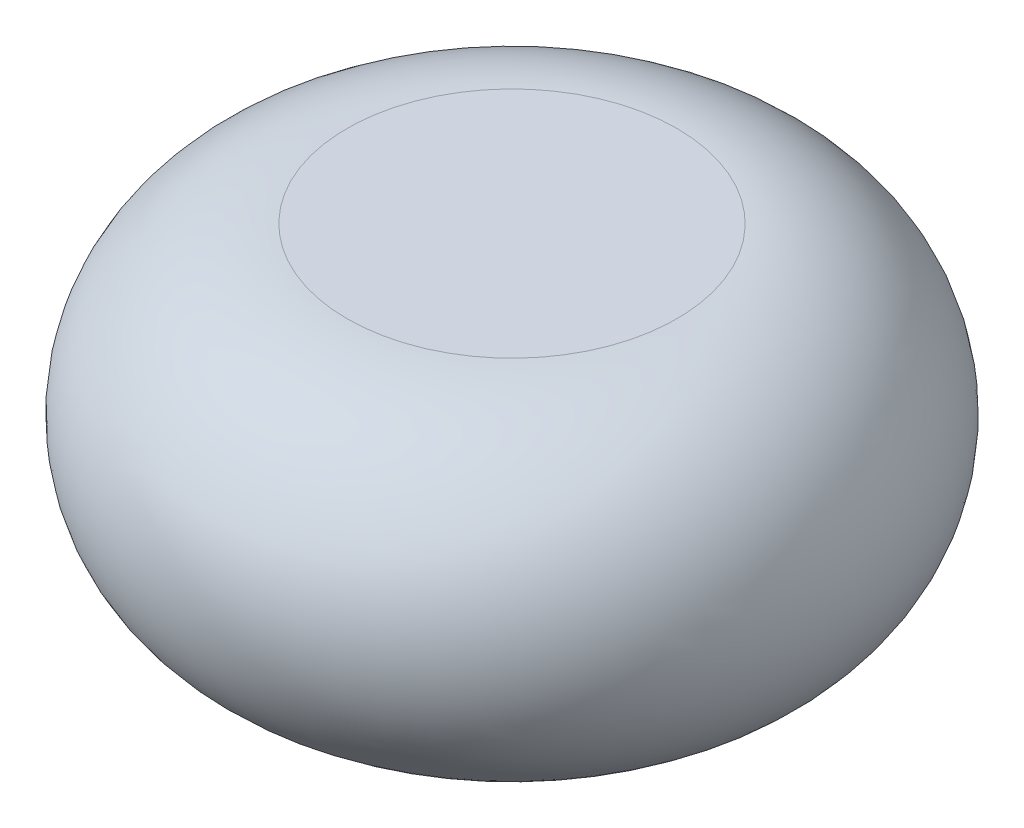
from build123d import *


with BuildPart() as part:
    # Sketch1 → Revolve2 (revolve)
    with BuildSketch(Plane.XY):
        with BuildLine():
            Line((0, 500), (0, -500))
            Line((0, -500), (500, -500))
            ThreePointArc((500, -500), (1000, 0), (500, 500))
            Line((500, 500), (0, 500))
        make_face()
    revolve(axis=Axis((0, 550, 0), (0, -1, 0)))


solid = part.part
